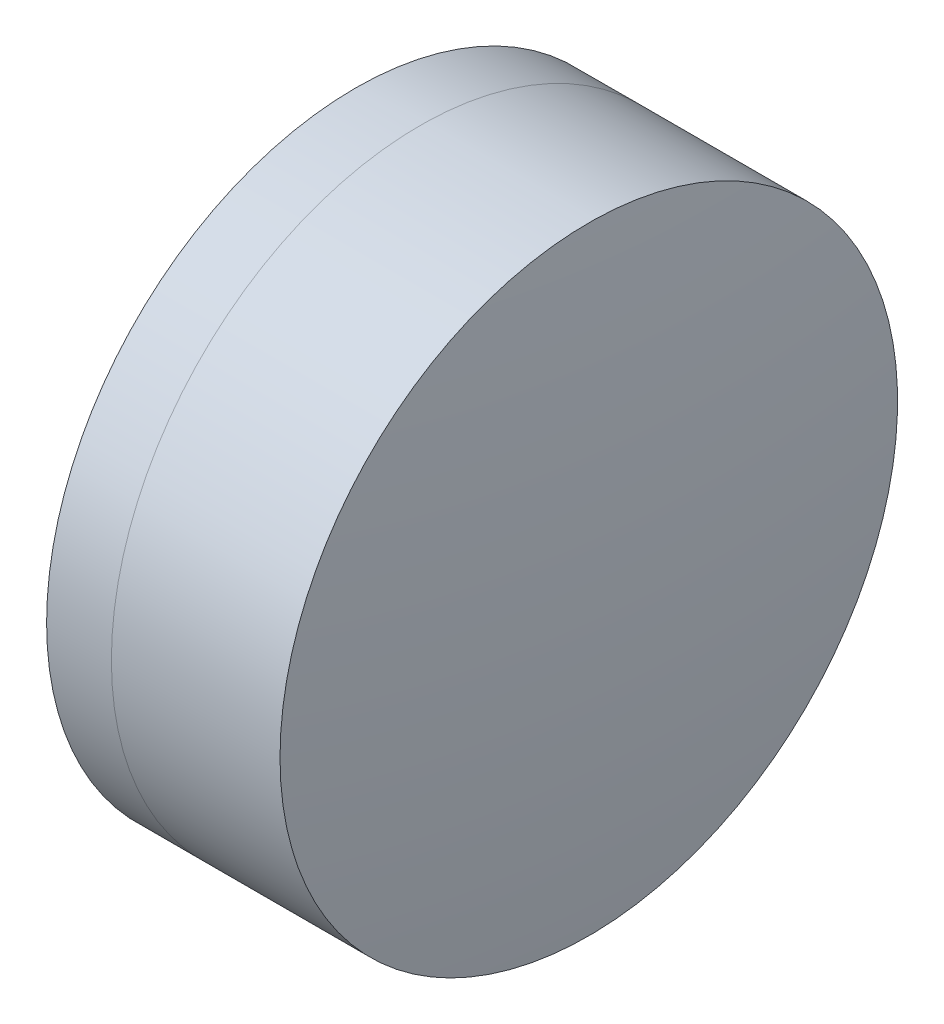
from build123d import *


with BuildPart() as part:
    # 草图1 one side → 旋转1 (revolve)
    with BuildSketch(Plane(origin=(0, 0, 0), x_dir=(1, 0, 0), z_dir=(0, 1, 0)), mode=Mode.PRIVATE) as revolve_1_sk:
        with BuildLine():
            ThreePointArc((0.816598139, 4), (0.258860466, 2.034464215), (0.070824329, 0))
            Line((0.070824329, 0), (2.570824329, 0))
            ThreePointArc((2.570824329, 0), (2.339138548, 2.051667632), (1.6557504, 4))
            Line((1.6557504, 4), (0.816598139, 4))
        make_face()
    revolve(revolve_1_sk.sketch.rotate(Axis((-9.702612178, 0, 0), (1, 0, 0)), 180), axis=Axis((-9.702612178, 0, 0), (1, 0, 0)))  # turned: the seam where the file's is


with BuildPart() as body_2:
    # 草图2 one side → 旋转3 (revolve)
    with BuildSketch(Plane(origin=(0, 0, 0), x_dir=(1, 0, 0), z_dir=(0, 1, 0)), mode=Mode.PRIVATE) as revolve_3_sk:
        with BuildLine():
            Line((3.840174916, 4), (1.6557504, 4))
            ThreePointArc((1.6557504, 4), (2.339138548, 2.051667632), (2.570824329, 0))
            Line((2.570824329, 0), (4.070824329, 0))
            ThreePointArc((4.070824329, 0), (4.013114124, 2.003322188), (3.840174916, 4))
        make_face()
    revolve(revolve_3_sk.sketch.rotate(Axis((-0.551919993, 0, 0), (1, 0, 0)), 180), axis=Axis((-0.551919993, 0, 0), (1, 0, 0)))  # turned: the seam where the file's is


solid = Compound([part.part, body_2.part])
